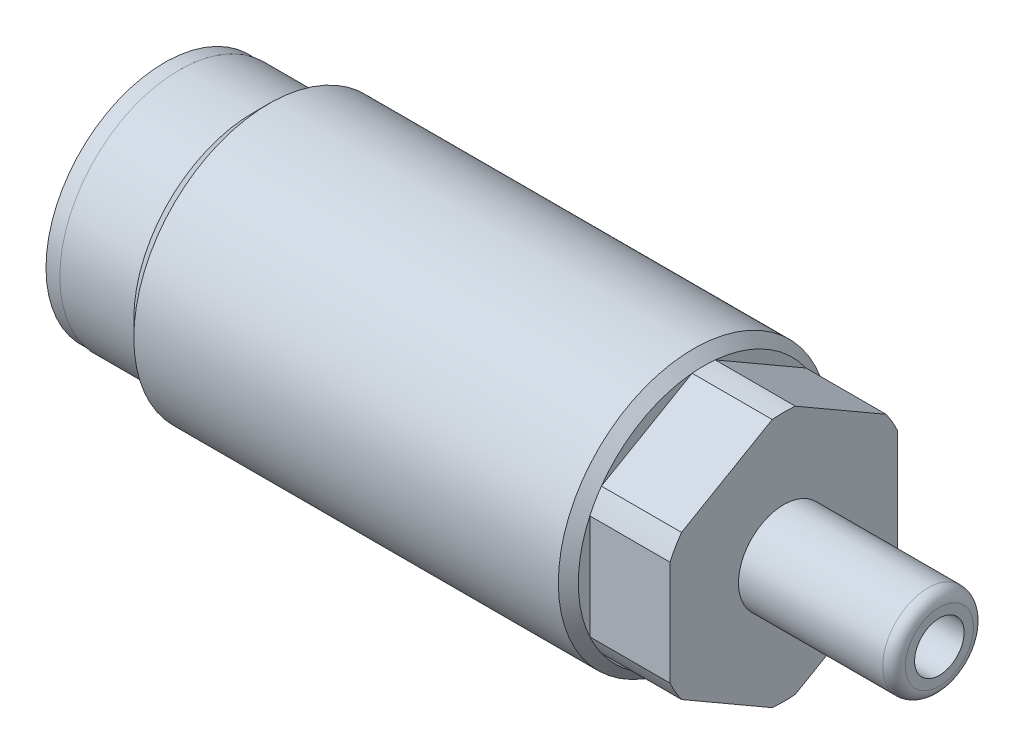
from build123d import *

# Parameters (mm, degrees)
SKETCH1_W                 = 42.164
SKETCH1_H                 = 9.4361
SKETCH2_W                 = 1.016
SKETCH2_H                 = 3.9624
CUT_EXTRUDE1_DEPTH        = 5.588
SKETCH6_W                 = 10.8458
SKETCH6_H                 = 3.1623
FILLET1_R                 = 0.7874
F_8_32_TAPPED_HOLE1_D     = 3.4544
F_8_32_TAPPED_HOLE1_DEPTH = 10.668
F_8_32_TAPPED_HOLE1_TIP   = 1.037806461
SKETCH12_W                = 1.016
SKETCH12_H                = 2.5273


with BuildPart() as part:
    # Sketch1 → Revolve1 (revolve)
    with BuildSketch(Plane.XY, mode=Mode.PRIVATE) as revolve1_sk:
        with Locations((21.082, 4.71805)):
            Rectangle(SKETCH1_W, SKETCH1_H)
    revolve(revolve1_sk.sketch.rotate(Axis((-25.954653295, 0, 0), (1, 0, 0)), 90), axis=Axis((-25.954653295, 0, 0), (1, 0, 0)))  # turned: the seam where the file's is

    # Sketch2 → Cut-Revolve1 (revolve, cut)
    with BuildSketch(Plane.XY, mode=Mode.PRIVATE) as cut_revolve1_sk:
        with Locations((0.508, 1.9812)):
            Rectangle(SKETCH2_W, SKETCH2_H)
    revolve(cut_revolve1_sk.sketch.rotate(Axis((-4.423867111, 0, 0), (1, 0, 0)), 90), axis=Axis((-4.423867111, 0, 0), (1, 0, 0)), mode=Mode.SUBTRACT)  # turned: the seam where the file's is

    # Sketch3 → Cut-Revolve2 (revolve, cut)
    with BuildSketch(Plane.XY, mode=Mode.PRIVATE) as cut_revolve2_sk:
        Polygon((0, 8.3185), (5.1562, 8.3185), (6.2738, 9.4361), (0, 9.4361), align=None)
    revolve(cut_revolve2_sk.sketch.rotate(Axis((-2.146557548, 0, 0), (1, 0, 0)), 90), axis=Axis((-2.146557548, 0, 0), (1, 0, 0)), mode=Mode.SUBTRACT)  # turned: the seam where the file's is

    # Sketch4 → Cut-Revolve3 (revolve, cut)
    with BuildSketch(Plane.XY, mode=Mode.PRIVATE) as cut_revolve3_sk:
        Polygon((42.164, 8.7376), (36.576, 8.7376), (35.8775, 9.4361), (42.164, 9.4361), align=None)
    revolve(cut_revolve3_sk.sketch.rotate(Axis((-3.32735082, 0, 0), (1, 0, 0)), 90), axis=Axis((-3.32735082, 0, 0), (1, 0, 0)), mode=Mode.SUBTRACT)  # turned: the seam where the file's is

    # Sketch5 → Cut-Extrude1 (cut)
    with BuildSketch(Plane(origin=(42.164, 0, 0), x_dir=(0, 0, -1), z_dir=(1, 0, 0))):
        with BuildLine():
            Line((-7.9375, -3.652635694), (-7.9375, 0))
            Line((-7.9375, 0), (-7.9375, 3.652635694))
            ThreePointArc((-7.9375, 3.652635694), (-8.7376, 0), (-7.9375, -3.652635694))
        make_face()
        with BuildLine():
            Line((-3.96875004, 6.874076619), (-0.805474699, 8.700394489))
            ThreePointArc((-0.805474699, 8.700394489), (-4.3688, 7.566983568), (-7.132025301, 5.047758796))
            Line((-7.132025301, 5.047758796), (-3.96875004, 6.874076619))
        make_face()
        with BuildLine():
            ThreePointArc((7.132025301, 5.047758796), (4.3688, 7.566983568), (0.805474699, 8.700394489))
            Line((0.805474699, 8.700394489), (3.968749933, 6.874076681))
            Line((3.968749933, 6.874076681), (7.132025301, 5.047758796))
        make_face()
        with BuildLine():
            Line((7.9375, 3.652635694), (7.9375, 0))
            Line((7.9375, 0), (7.9375, -3.652635694))
            ThreePointArc((7.9375, -3.652635694), (8.535231507, -1.869619448), (8.7376, 0))
            ThreePointArc((8.7376, 0), (8.535231507, 1.869619448), (7.9375, 3.652635694))
        make_face()
        with BuildLine():
            Line((7.132025301, -5.047758796), (3.968749899, -6.874076701))
            Line((3.968749899, -6.874076701), (0.805474699, -8.700394489))
            ThreePointArc((0.805474699, -8.700394489), (4.3688, -7.566983568), (7.132025301, -5.047758796))
        make_face()
        with BuildLine():
            Line((-0.805474699, -8.700394489), (-3.96875004, -6.874076619))
            Line((-3.96875004, -6.874076619), (-7.132025301, -5.047758796))
            ThreePointArc((-7.132025301, -5.047758796), (-4.3688, -7.566983568), (-0.805474699, -8.700394489))
        make_face()
    extrude(amount=-CUT_EXTRUDE1_DEPTH, mode=Mode.SUBTRACT)

    # Sketch6 → Revolve3 (revolve)
    with BuildSketch(Plane.XY, mode=Mode.PRIVATE) as revolve3_sk:
        with Locations((47.5869, 1.58115)):
            Rectangle(SKETCH6_W, SKETCH6_H)
    revolve(revolve3_sk.sketch.rotate(Axis((-1.691095635, 0, 0), (1, 0, 0)), 90), axis=Axis((-1.691095635, 0, 0), (1, 0, 0)))  # turned: the seam where the file's is

    # Fillet1
    fillet1_edges = [part.edges().sort_by_distance(p)[0] for p in [
        (53.0098, 0, -3.1623),
    ]]
    fillet(fillet1_edges, radius=FILLET1_R)

    # #8-32 Tapped Hole1
    with Locations(Plane(origin=(53.0098, 0, 0), x_dir=(0, 0, -1), z_dir=(1, 0, 0))):
        with Locations((0, 0)):
            Hole(F_8_32_TAPPED_HOLE1_D / 2, depth=F_8_32_TAPPED_HOLE1_DEPTH)
            with Locations((0, 0, -(F_8_32_TAPPED_HOLE1_DEPTH + F_8_32_TAPPED_HOLE1_TIP / 2))):  # 118° drill point
                Cone(0, F_8_32_TAPPED_HOLE1_D / 2, F_8_32_TAPPED_HOLE1_TIP, mode=Mode.SUBTRACT)

    # Sketch12 → Revolve4 (revolve)
    with BuildSketch(Plane.XY, mode=Mode.PRIVATE) as revolve4_sk:
        with Locations((-0.508, 7.00405)):
            Rectangle(SKETCH12_W, SKETCH12_H)
    revolve(revolve4_sk.sketch.rotate(Axis((-4.807110581, 0, 0), (1, 0, 0)), 90), axis=Axis((-4.807110581, 0, 0), (1, 0, 0)))  # turned: the seam where the file's is


solid = part.part
